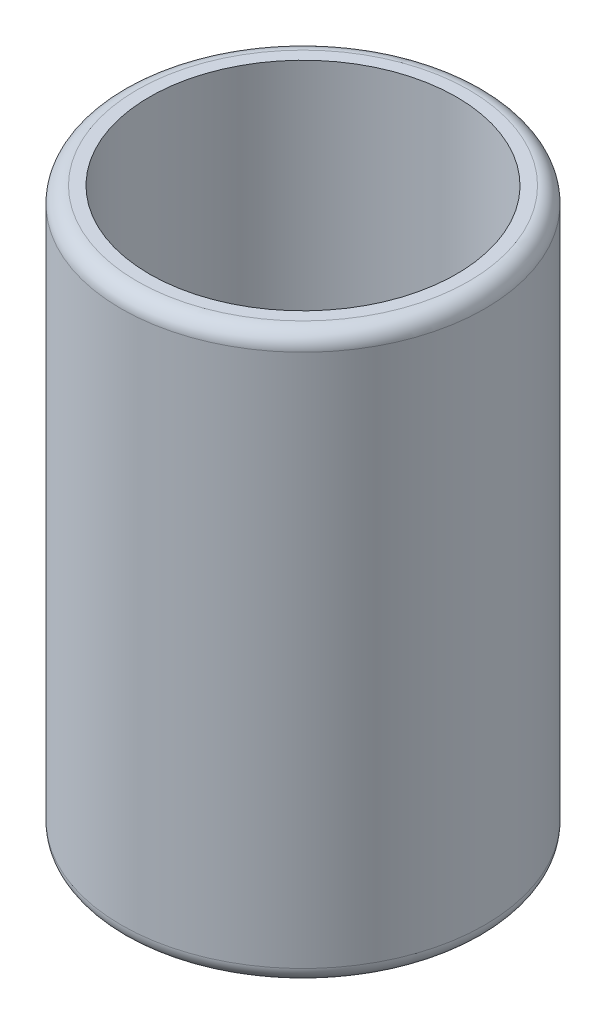
from build123d import *

# Parameters (mm, degrees)
SKETCH1_R           = 57.15
BOSS_EXTRUDE1_DEPTH = 8.89
SKETCH1_4_R         = 57.15
SKETCH1_4_R_2       = 48.26
BOSS_EXTRUDE2_DEPTH = 177.8
FILLET1_R           = 5


with BuildPart() as part:
    # Sketch1 → Boss-Extrude1 (new body)
    with BuildSketch(Plane(origin=(0, 0, 0), x_dir=(1, 0, 0), z_dir=(0, 1, 0))):
        Circle(SKETCH1_R)
    extrude(amount=BOSS_EXTRUDE1_DEPTH)

    # Sketch1_4 → Boss-Extrude2 (add)
    with BuildSketch(Plane(origin=(0, 0, 0), x_dir=(1, 0, 0), z_dir=(0, 1, 0))):
        Circle(SKETCH1_4_R)
        Circle(SKETCH1_4_R_2, mode=Mode.SUBTRACT)
    extrude(amount=BOSS_EXTRUDE2_DEPTH)

    # Fillet1
    fillet1_edges = [part.edges().sort_by_distance(p)[0] for p in [
        (-57.15, 0, 0),
        (-57.15, 177.8, 0),
    ]]
    fillet(fillet1_edges, radius=FILLET1_R)


solid = part.part
